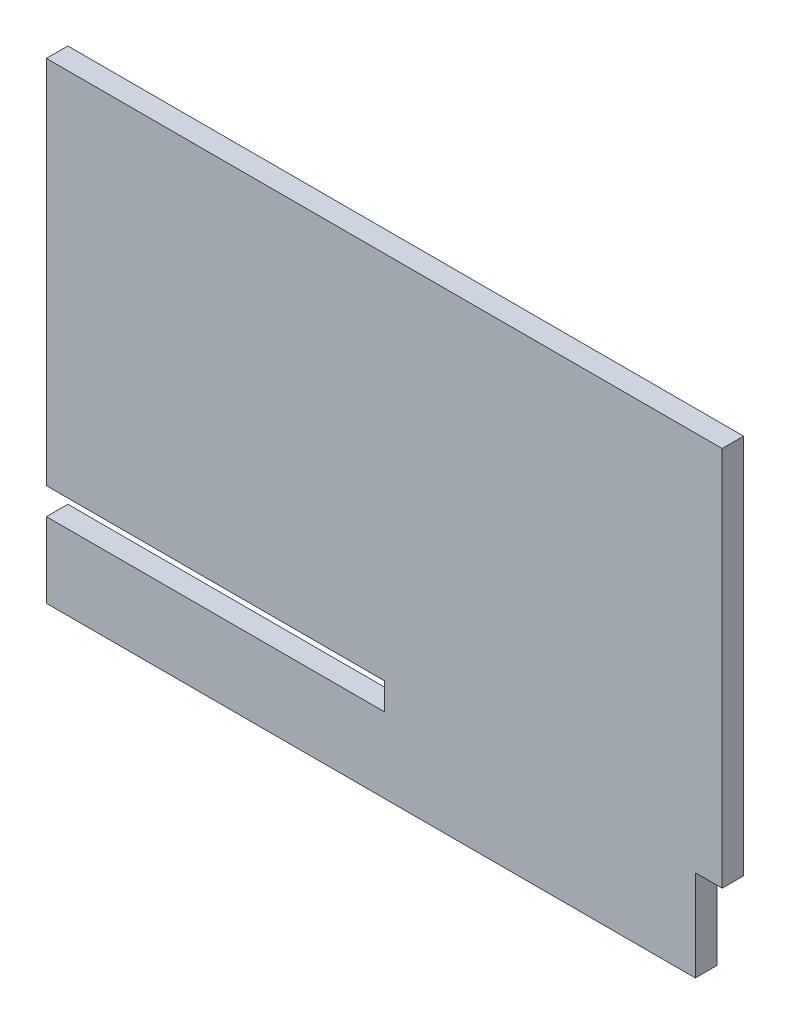
from build123d import *

# Parameters (mm, degrees)
BOSS_EXTRUDE1_DEPTH = 20
SKETCH2_W           = 630
SKETCH2_H           = 25
CUT_EXTRUDE1_DEPTH  = 40


with BuildPart() as part:
    # Sketch1 → Boss-Extrude1 (new body)
    with BuildSketch(Plane.XY):
        Polygon((315, -135), (290, -135), (290, -220), (-315, -220), (-315, 220), (315, 220), align=None)
    extrude(amount=BOSS_EXTRUDE1_DEPTH)

    # Sketch2 → Cut-Extrude1 (cut)
    with BuildSketch(Plane.XY.offset(20)):
        with Locations((-315, -137.5)):
            Rectangle(SKETCH2_W, SKETCH2_H)
    extrude(amount=-CUT_EXTRUDE1_DEPTH, mode=Mode.SUBTRACT)


solid = part.part
